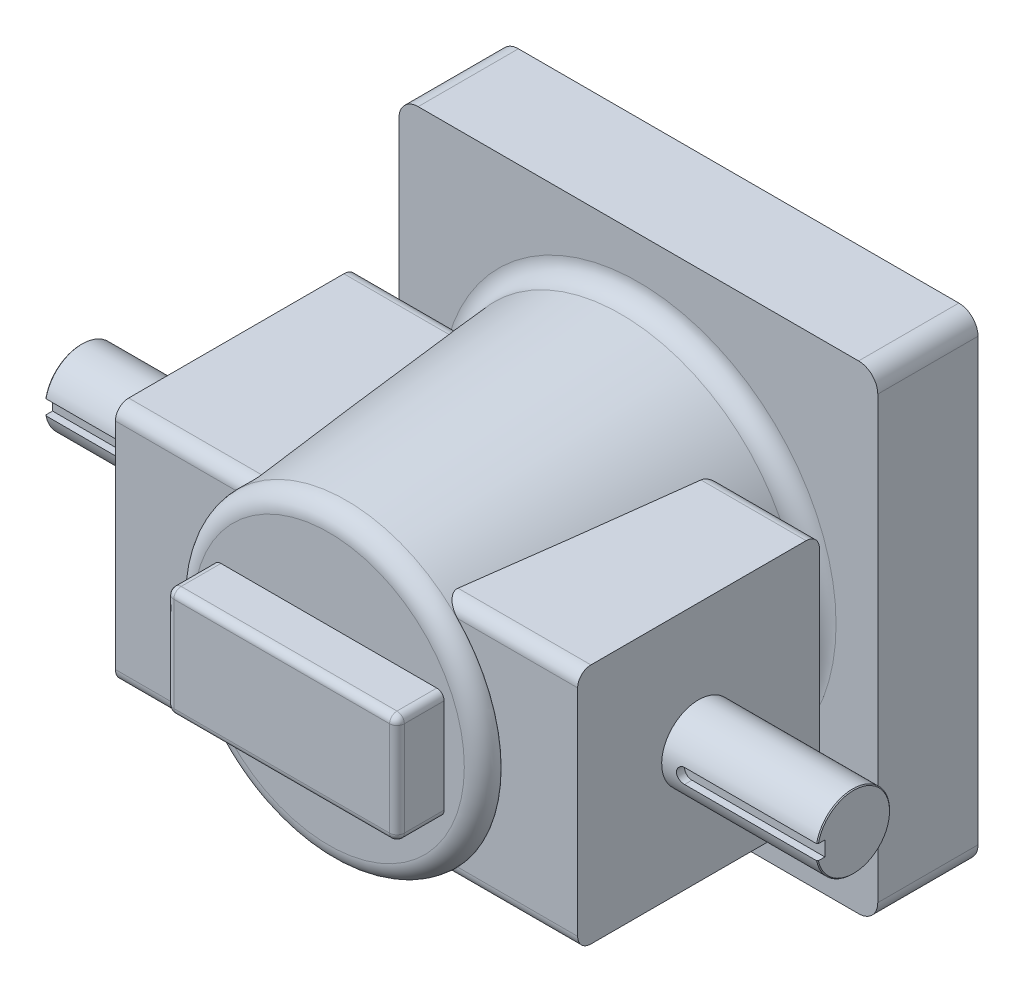
from build123d import *

# Parameters (mm, degrees)
SKETCH1_W           = 206.248
SKETCH1_H           = 206.248
C_DIM_DEPTH         = 43.18
SHAFT_START         = 12.7
SKETCH_A_R          = 15.875
SHAFT_DEPTH         = 153.67
SKETCH3_W           = 104.14
SKETCH3_H           = 104.14
BOSS_EXTRUDE3_DEPTH = 99.568
FILLET1_R           = 5.715
FILLET4_R           = 5.715
SKETCH4_R           = 77.597
BOSS_EXTRUDE4_DEPTH = 133.35
BOSS_EXTRUDE4_TAPER = 5
FILLET2_R           = 8.255
SKETCH5_W           = 99.328405226
SKETCH5_H           = 47.124202614
BOSS_EXTRUDE5_DEPTH = 20.32
CHAMFER1_SIZE       = 0.381
FILLET3_R           = 3.175
CUT_EXTRUDE_START   = 12.3698
CUT_EXTRUDE_B_DEPTH = 68.6402


with BuildPart() as part:
    # Sketch1 → C dim (new body)
    with BuildSketch(Plane.XY):
        Rectangle(SKETCH1_W, SKETCH1_H)
    extrude(amount=C_DIM_DEPTH)



with BuildPart() as body_2:
    # Sketch A → Shaft (new body)
    with BuildSketch(Plane(origin=(0, 0, 0), x_dir=(0, 0, -1), z_dir=(1, 0, 0)).offset(SHAFT_START)):
        with Locations((-116.84, 0)):
            Circle(SKETCH_A_R)
    extrude(amount=SHAFT_DEPTH)

    # Chamfer1
    chamfer1_edges = [body_2.edges().sort_by_distance(p)[0] for p in [
        (166.37, 0, 132.715),
    ]]
    chamfer(chamfer1_edges, length=CHAMFER1_SIZE)

    # Sketch6 → Cut-Extrude B (cut, through all)
    with BuildSketch(Plane.XY.offset(116.84).offset(CUT_EXTRUDE_START)):
        with BuildLine():
            Line((166.37, -3.175), (109.093, -3.175))
            ThreePointArc((109.093, -3.175), (105.918, 0), (109.093, 3.175))
            Line((109.093, 3.175), (166.37, 3.175))
            ThreePointArc((166.37, 3.175), (169.545, 0), (166.37, -3.175))
        make_face()
    extrude(amount=CUT_EXTRUDE_B_DEPTH, mode=Mode.SUBTRACT)


with BuildPart() as body_3:
    # Sketch3 → Boss-Extrude3 (new body)
    with BuildSketch(Plane(origin=(0, 0, 0), x_dir=(0, 0, -1), z_dir=(1, 0, 0))):
        with Locations((-116.84, 0)):
            Rectangle(SKETCH3_W, SKETCH3_H)
    extrude(amount=BOSS_EXTRUDE3_DEPTH)


with BuildPart() as body_4:
    # Mirror2: mirrored copy
    add(body_3.part.mirror(Plane(origin=(0, 0, 0), x_dir=(0, 0, 1), z_dir=(1, 0, 0))))

    # Fillet4
    fillet4_edges = [body_4.edges().sort_by_distance(p)[0] for p in [
        (-49.784, 52.07, 64.77),
        (-49.784, 52.07, 168.91),
        (-49.784, -52.07, 168.91),
        (-49.784, -52.07, 64.77),
    ]]
    fillet(fillet4_edges, radius=FILLET4_R)


with BuildPart() as body_3_1:
    add(body_3.part)

    # Fillet1
    fillet1_edges = [body_3_1.edges().sort_by_distance(p)[0] for p in [
        (49.784, 52.07, 64.77),
        (49.784, 52.07, 168.91),
        (49.784, -52.07, 168.91),
        (49.784, -52.07, 64.77),
    ]]
    fillet(fillet1_edges, radius=FILLET1_R)


with BuildPart() as part_1:
    add(part.part)

    add(body_3_1.part)  # Boss-Extrude4 merges body 3

    add(body_4.part)  # Boss-Extrude4 merges body 4
    # Sketch4 → Boss-Extrude4 (add)
    with BuildSketch(Plane.XY.offset(43.18)):
        Circle(SKETCH4_R)
    extrude(amount=BOSS_EXTRUDE4_DEPTH, taper=BOSS_EXTRUDE4_TAPER)

    # Fillet2
    fillet2_edges = [part_1.edges().sort_by_distance(p)[0] for p in [
        (-65.930386719, 0, 176.53),
        (-77.597, 0, 43.18),
        (-103.124, 103.124, 21.59),
        (103.124, 103.124, 21.59),
        (103.124, -103.124, 21.59),
        (-103.124, -103.124, 21.59),
    ]]
    fillet(fillet2_edges, radius=FILLET2_R)

    # Sketch5 → Boss-Extrude5 (add)
    with BuildSketch(Plane.XY.offset(176.53)):
        Rectangle(SKETCH5_W, SKETCH5_H)
    extrude(amount=BOSS_EXTRUDE5_DEPTH)

    # Fillet3
    fillet3_edges = [part_1.edges().sort_by_distance(p)[0] for p in [
        (-49.664202613, 23.562101307, 186.69),
        (-49.664202613, -23.562101307, 186.69),
        (49.664202613, -23.562101307, 186.69),
        (49.664202613, 23.562101307, 186.69),
        (0, 23.562101307, 196.85),
        (-49.664202613, 0, 196.85),
        (0, -23.562101307, 196.85),
        (49.664202613, 0, 196.85),
    ]]
    fillet(fillet3_edges, radius=FILLET3_R)


with BuildPart() as body_3_2:
    # Mirror6: mirrored copy
    add(body_2.part.mirror(Plane(origin=(0, 0, 0), x_dir=(0, 0, 1), z_dir=(1, 0, 0))))


with BuildPart() as part_2:
    add(part_1.part)

    # Combine1: union body 2, body 3 2
    add(body_2.part)
    add(body_3_2.part)


solid = part_2.part
